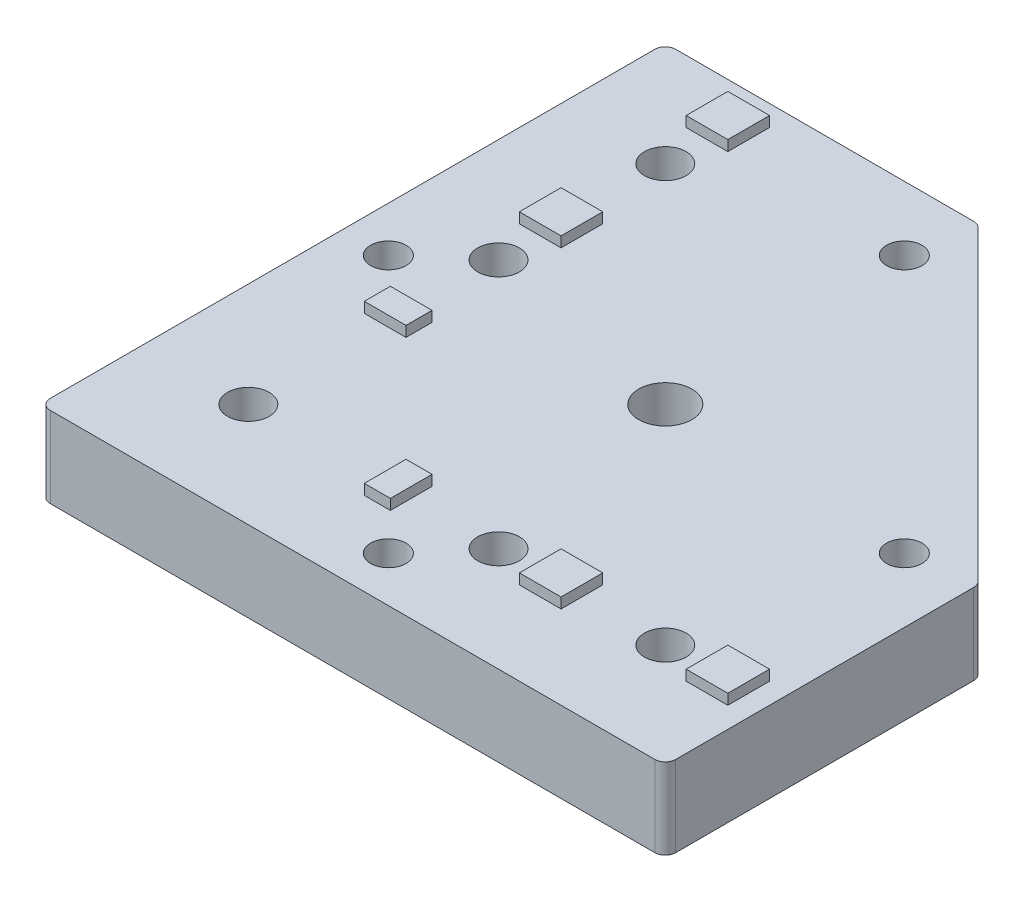
from build123d import *

# Parameters (mm, degrees)
EXTRUDE_1_DEPTH           = 15.5
HOLE_WIZARD_M121_D        = 10.2
HOLE_WIZARD_M121_DEPTH    = 15.5
HOLE_WIZARD_M82_D         = 6.8
HOLE_WIZARD_M82_DEPTH     = 15.5
HOLE_WIZARD_8_0_8_1_D     = 8
HOLE_WIZARD_8_0_8_1_DEPTH = 15.5
SKETCH_9_W                = 8
SKETCH_9_H                = 8
SKETCH_9_H_2              = 5
SKETCH_9_W_2              = 5
EXTRUDE_2_DEPTH           = 2
FILLET_1_R                = 2


with BuildPart() as part:
    # Эскиз1 → Бобышка-Вытянуть1 (new body)
    with BuildSketch(Plane(origin=(0, 0, 0), x_dir=(1, 0, 0), z_dir=(0, 1, 0))):
        Polygon((0, 0), (0, 120), (60, 120), (120, 60), (120, 0), align=None)
    extrude(amount=EXTRUDE_1_DEPTH)

    # Отверстие обработанное метчиком M121
    with Locations(Plane(origin=(0, 15.5, 0), x_dir=(1, 0, 0), z_dir=(0, 1, 0))):
        with Locations((60, 60)):
            Hole(HOLE_WIZARD_M121_D / 2, depth=HOLE_WIZARD_M121_DEPTH)

    # Отверстие обработанное метчиком M82
    with Locations(Plane(origin=(0, 15.5, 0), x_dir=(1, 0, 0), z_dir=(0, 1, 0))):
        with Locations((58.180194847, 107.67766953), (107.67766953, 58.180194847), (58.180194847, 8.682720164), (8.682720164, 58.180194847)):
            Hole(HOLE_WIZARD_M82_D / 2, depth=HOLE_WIZARD_M82_DEPTH)

    # Диаметр отверстия Ø8.0 (8)1
    with Locations(Plane(origin=(0, 15.5, 0), x_dir=(1, 0, 0), z_dir=(0, 1, 0))):
        with Locations((20, 100), (20, 68), (20, 20), (68, 20), (100, 20)):
            Hole(HOLE_WIZARD_8_0_8_1_D / 2, depth=HOLE_WIZARD_8_0_8_1_DEPTH)

    # Эскиз9 → Бобышка-Вытянуть2 (add)
    with BuildSketch(Plane(origin=(0, 15.5, 0), x_dir=(1, 0, 0), z_dir=(0, 1, 0))):
        with Locations((20, 112)):
            Rectangle(SKETCH_9_W, SKETCH_9_H)
        with Locations((20, 80)):
            Rectangle(SKETCH_9_W, SKETCH_9_H)
        with Locations((20, 48.75)):
            Rectangle(SKETCH_9_W, SKETCH_9_H_2)
        with Locations((48.75, 20)):
            Rectangle(SKETCH_9_W_2, SKETCH_9_H)
        with Locations((80, 20)):
            Rectangle(SKETCH_9_W, SKETCH_9_H)
        with Locations((112, 20)):
            Rectangle(SKETCH_9_W, SKETCH_9_H)
    extrude(amount=EXTRUDE_2_DEPTH)

    # Скругление1
    fillet_1_edges = [part.edges().sort_by_distance(p)[0] for p in [
        (0, 7.75, 0),
        (0, 7.75, -120),
        (60, 7.75, -120),
        (120, 7.75, -60),
        (120, 7.75, 0),
    ]]
    fillet(fillet_1_edges, radius=FILLET_1_R)


solid = part.part
